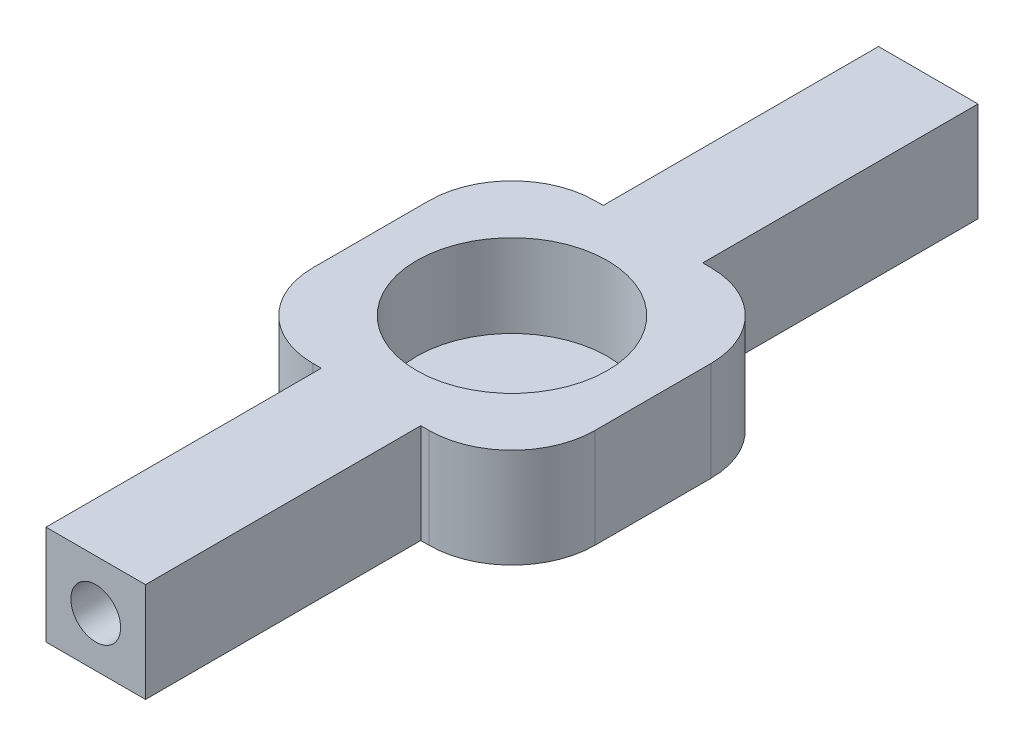
from build123d import *

# Parameters (mm, degrees)
SKETCH1_R           = 5.75
BOSS_EXTRUDE1_DEPTH = 6
SKETCH8_W           = 17
SKETCH8_H           = 17
BOSS_EXTRUDE6_DEPTH = 1
FILLET1_R           = 5
SKETCH9_R           = 1.5
CUT_EXTRUDE2_DEPTH  = 5
SKETCH10_R          = 1.5
CUT_EXTRUDE3_DEPTH  = 5


with BuildPart() as part:
    # Sketch1 → Boss-Extrude1 (new body)
    with BuildSketch(Plane(origin=(0, 0, 0), x_dir=(1, 0, 0), z_dir=(0, 1, 0))):
        Polygon((8.5, 8.5), (3, 8.5), (3, 25.1), (-3, 25.1), (-3, 8.5), (-8.5, 8.5), (-8.5, -8.5), (-3, -8.5), (-3, -25.1), (3, -25.1), (3, -8.5), (8.5, -8.5), align=None)
        Circle(SKETCH1_R, mode=Mode.SUBTRACT)
    extrude(amount=BOSS_EXTRUDE1_DEPTH)

    # Sketch8 → Boss-Extrude6 (add)
    with BuildSketch(Plane.XZ):
        Rectangle(SKETCH8_W, SKETCH8_H)
    extrude(amount=-BOSS_EXTRUDE6_DEPTH)

    # Fillet1
    fillet1_edges = [part.edges().sort_by_distance(p)[0] for p in [
        (8.5, 3, -8.5),
        (-8.5, 3, -8.5),
        (-8.5, 3, 8.5),
        (8.5, 3, 8.5),
    ]]
    fillet(fillet1_edges, radius=FILLET1_R)

    # Sketch9 → Cut-Extrude2 (cut)
    with BuildSketch(Plane(origin=(0, 0, -25.1), x_dir=(-1, 0, 0), z_dir=(0, 0, -1))):
        with Locations((0, 3)):
            Circle(SKETCH9_R)
    extrude(amount=-CUT_EXTRUDE2_DEPTH, mode=Mode.SUBTRACT)

    # Sketch10 → Cut-Extrude3 (cut)
    with BuildSketch(Plane.XY.offset(25.1)):
        with Locations((0, 3)):
            Circle(SKETCH10_R)
    extrude(amount=-CUT_EXTRUDE3_DEPTH, mode=Mode.SUBTRACT)


solid = part.part
